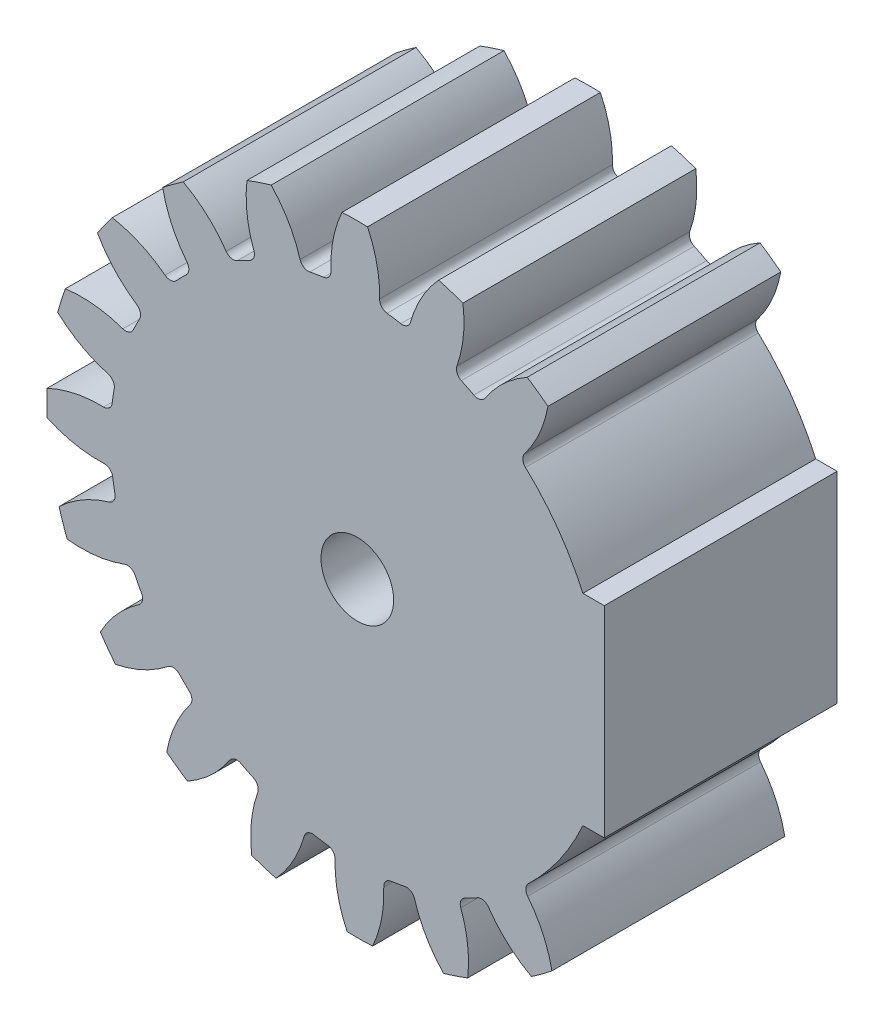
from build123d import *

# Parameters (mm, degrees)
SKBASE_R                                = 22
BASE_DEPTH                              = 8.25
TOOTHPROFILE_DEPTH                      = 9.25
FILLETTOOTHPROFILE_R                    = 0.6
CIRPATTERNTEETH_COUNT                   = 20
FILLETTOOTHPROFILE_OF_CIRPATTERNTEETH_R = 0.6
SKCHAVETA_R                             = 2.575
CHAVETA_DEPTH                           = 17.5000001
BODY_MOVE_COPY1_ANGLE                   = 9.47
CUT_EXTRUDE1_DEPTH                      = 16.5
SKETCH8_W                               = 14.925
SKETCH8_H                               = 14.25
BOSS_EXTRUDE1_DEPTH                     = 16.5


with BuildPart() as part:
    # skBase → Base (new body, symmetric)
    with BuildSketch(Plane.XY):
        Circle(SKBASE_R)
    extrude(amount=BASE_DEPTH, both=True)

    # skToothProfile → ToothProfile (cut, symmetric)
    with BuildSketch(Plane.XY):
        with BuildLine():
            ThreePointArc((-1.056260379, 17.468094172), (-1.711312383, 20.303280592), (-3.25795804, 22.768085326))
            ThreePointArc((-3.25795804, 22.768085326), (0, 23), (3.25795804, 22.768085326))
            ThreePointArc((3.25795804, 22.768085326), (1.711312383, 20.303280592), (1.056260379, 17.468094172))
            ThreePointArc((1.056260379, 17.468094172), (0, 17.5), (-1.056260379, 17.468094172))
        make_face()
    toothprofile = extrude(amount=TOOTHPROFILE_DEPTH, both=True, mode=Mode.SUBTRACT)

    # FilletToothProfile
    fillettoothprofile_edges = [part.edges().sort_by_distance(p)[0] for p in [
        (-1.056260379, 17.468094172, 0),
        (1.056260379, 17.468094172, 0),
    ]]
    fillet(fillettoothprofile_edges, radius=FILLETTOOTHPROFILE_R)

    # CirPatternTeeth: ToothProfile ×20 about axis
    cirpatternteeth_axis = Axis((0, 0, 0), (0, 0, 1))
    for i in range(1, CIRPATTERNTEETH_COUNT):
        add(toothprofile.rotate(cirpatternteeth_axis, i * 360 / CIRPATTERNTEETH_COUNT), mode=Mode.SUBTRACT)

    # FilletToothProfile of CirPatternTeeth
    fillettoothprofile_of_cirpatternteeth_edges = [part.edges().sort_by_distance(p)[0] for p in [
        (-6.402501275, 16.286742382, 0),
        (-4.393374642, 16.939547198, 0),
        (-11.122020738, 13.511130771, 0),
        (-9.412955543, 14.752839318, 0),
        (-14.752839318, 9.412955543, 0),
        (-13.511130771, 11.122020738, 0),
        (-16.939547198, 4.393374642, 0),
        (-16.286742382, 6.402501275, 0),
        (-17.468094172, -1.056260379, 0),
        (-17.468094172, 1.056260379, 0),
        (-16.286742382, -6.402501275, 0),
        (-16.939547198, -4.393374642, 0),
        (-13.511130771, -11.122020738, 0),
        (-14.752839318, -9.412955543, 0),
        (-9.412955543, -14.752839318, 0),
        (-11.122020738, -13.511130771, 0),
        (-4.393374642, -16.939547198, 0),
        (-6.402501275, -16.286742382, 0),
        (1.056260379, -17.468094172, 0),
        (-1.056260379, -17.468094172, 0),
        (6.402501275, -16.286742382, 0),
        (4.393374642, -16.939547198, 0),
        (11.122020738, -13.511130771, 0),
        (9.412955543, -14.752839318, 0),
        (14.752839318, -9.412955543, 0),
        (13.511130771, -11.122020738, 0),
        (16.939547198, -4.393374642, 0),
        (16.286742382, -6.402501275, 0),
        (17.468094172, 1.056260379, 0),
        (17.468094172, -1.056260379, 0),
        (16.286742382, 6.402501275, 0),
        (16.939547198, 4.393374642, 0),
        (13.511130771, 11.122020738, 0),
        (14.752839318, 9.412955543, 0),
        (9.412955543, 14.752839318, 0),
        (11.122020738, 13.511130771, 0),
        (4.393374642, 16.939547198, 0),
        (6.402501275, 16.286742382, 0),
    ]]
    fillet(fillettoothprofile_of_cirpatternteeth_edges, radius=FILLETTOOTHPROFILE_OF_CIRPATTERNTEETH_R)

    # skChaveta → Chaveta (cut, through all)
    with BuildSketch(Plane.XY.offset(8.25)):
        Circle(SKCHAVETA_R)
    extrude(amount=-CHAVETA_DEPTH, mode=Mode.SUBTRACT)


with BuildPart() as part_1:
    # Body-Move/Copy1: moved
    add(part.part.rotate(Axis((0, 0, 0), (0, 0, 1)), BODY_MOVE_COPY1_ANGLE))

    # Sketch7 → Cut-Extrude1 (cut)
    with BuildSketch(Plane(origin=(0, 0, -8.25), x_dir=(-1, 0, 0), z_dir=(0, 0, -1))):
        with BuildLine():
            ThreePointArc((-17.173226329, 3.36605072), (-16.598569147, 5.544141257), (-15.748887399, 7.630369957))
            ThreePointArc((-15.748887399, 7.630369957), (-16.065279422, 7.33519136), (-16.497949068, 7.329597305))
            ThreePointArc((-16.497949068, 7.329597305), (-18.501273041, 7.815957796), (-20.562783523, 7.821248862))
            ThreePointArc((-20.562783523, 7.821248862), (-20.866772642, 6.96977758), (-21.135520509, 6.106535255))
            ThreePointArc((-21.135520509, 6.106535255), (-19.484646916, 4.871841023), (-17.591167465, 4.056617719))
            ThreePointArc((-17.591167465, 4.056617719), (-17.248711541, 3.792121488), (-17.173226329, 3.36605072))
        make_face()
        with BuildLine():
            ThreePointArc((-17.372875683, -2.105514312), (-17.499411216, 0.143551721), (-17.335995976, 2.390239221))
            ThreePointArc((-17.335995976, 2.390239221), (-17.545687468, 2.011737181), (-17.955452096, 1.872714644))
            ThreePointArc((-17.955452096, 1.872714644), (-20.011020071, 1.716209805), (-21.973268079, 1.084200136))
            ThreePointArc((-21.973268079, 1.084200136), (-21.999259814, 0.180465021), (-21.988097676, -0.723574876))
            ThreePointArc((-21.988097676, -0.723574876), (-20.036482087, -1.387690875), (-17.983758262, -1.577896982))
            ThreePointArc((-17.983758262, -1.577896982), (-17.576329493, -1.723623146), (-17.372875683, -2.105514312))
        make_face()
        with BuildLine():
            ThreePointArc((-16.6159735, -7.057956132), (-16.183453853, -7.070647536), (-15.87194692, -7.370976934))
            ThreePointArc((-15.87194692, -7.370976934), (-16.68728899, -5.271089658), (-17.226136479, -3.083864784))
            ThreePointArc((-17.226136479, -3.083864784), (-17.308601376, -3.508639851), (-17.655350369, -3.767482374))
            ThreePointArc((-17.655350369, -3.767482374), (-19.561949032, -4.551532758), (-21.232856058, -5.758977654))
            ThreePointArc((-21.232856058, -5.758977654), (-20.978306158, -6.626512712), (-20.688326642, -7.482856457))
            ThreePointArc((-20.688326642, -7.482856457), (-18.627006789, -7.511385922), (-16.6159735, -7.057956132))
        make_face()
        with BuildLine():
            ThreePointArc((-15.292541929, 8.508123256), (-14.072943481, 10.402031618), (-12.620167995, 12.123586919))
            ThreePointArc((-12.620167995, 12.123586919), (-13.012289893, 11.940625902), (-13.425511838, 12.069007913))
            ThreePointArc((-13.425511838, 12.069007913), (-15.180492499, 13.15062538), (-17.139470447, 13.792699256))
            ThreePointArc((-17.139470447, 13.792699256), (-17.691700376, 13.076839749), (-18.214051335, 12.338895168))
            ThreePointArc((-18.214051335, 12.338895168), (-17.025518747, 10.654483178), (-15.476630632, 9.294042413))
            ThreePointArc((-15.476630632, 9.294042413), (-15.232669524, 8.936666849), (-15.292541929, 8.508123256))
        make_face()
        with BuildLine():
            ThreePointArc((-13.621701481, -11.847133361), (-13.206428993, -11.725547682), (-12.817361407, -11.914916976))
            ThreePointArc((-12.817361407, -11.914916976), (-14.24169865, -10.169760055), (-15.430062722, -8.256098618))
            ThreePointArc((-15.430062722, -8.256098618), (-15.377228786, -8.685566767), (-15.627019937, -9.038891968))
            ThreePointArc((-15.627019937, -9.038891968), (-17.198018126, -10.373739583), (-18.414024148, -12.038426586))
            ThreePointArc((-18.414024148, -12.038426586), (-17.903849731, -12.784841212), (-17.363438053, -13.509663911))
            ThreePointArc((-17.363438053, -13.509663911), (-15.394190285, -12.899814179), (-13.621701481, -11.847133361))
        make_face()
    extrude(amount=-CUT_EXTRUDE1_DEPTH, mode=Mode.SUBTRACT)

    # Sketch8 → Boss-Extrude1 (add)
    with BuildSketch(Plane(origin=(0, 0, -8.25), x_dir=(-1, 0, 0), z_dir=(0, 0, -1))):
        with Locations((-10.0375, 0)):
            Rectangle(SKETCH8_W, SKETCH8_H)
    extrude(amount=-BOSS_EXTRUDE1_DEPTH)


solid = part_1.part
